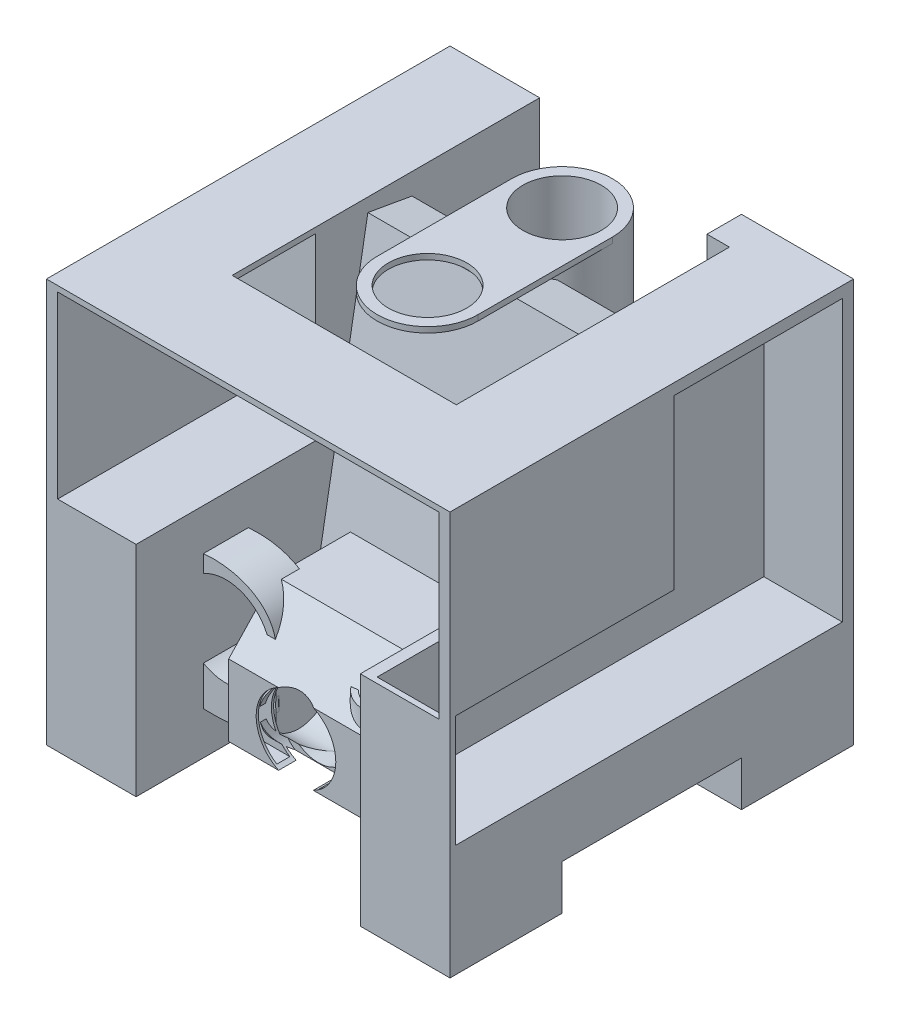
from build123d import *

# Parameters (mm, degrees)
SKETCH1_W               = 101.6
SKETCH1_H               = 457.2
BOSS_EXTRUDE1_DEPTH     = 457.2
BOSS_EXTRUDE1_2_DEPTH   = 457.2
BOSS_EXTRUDE2_DEPTH     = 127
BOSS_EXTRUDE3_DEPTH     = 127
SKETCH5_R               = 44.45
BOSS_EXTRUDE4_DEPTH     = 6.35
SKETCH6_R               = 57.15
SKETCH6_R_2             = 44.45
BOSS_EXTRUDE5_DEPTH     = 304.8
SKETCH8_R               = 50.8
BOSS_EXTRUDE6_DEPTH     = 25.4
SKETCH9_R               = 44.45
SKETCH9_R_2             = 38.1
SKETCH10_R              = 38.1
CUT_EXTRUDE4_DEPTH      = 628.365860165
SKETCH14_W              = 203.2
SKETCH14_H              = 203.2
CUT_EXTRUDE6_DEPTH      = 342.9
CUT_EXTRUDE6_DEPTH_BACK = 88.9
SKETCH15_W              = 108.742622592
SKETCH15_H              = 6.35
BOSS_EXTRUDE7_DEPTH     = 254
CUT_EXTRUDE7_DEPTH      = 88.9
SKETCH17_W              = 203.2
SKETCH17_H              = 50.8
CUT_EXTRUDE9_DEPTH      = 691.049565249
SKETCH18_W              = 39.02210791
SKETCH18_H              = 325.818088277
BOSS_EXTRUDE8_DEPTH     = 25.4
EXTRUDE_THIN1_DEPTH     = 203.2
SKETCH21_R              = 45.128499214
CUT_EXTRUDE10_DEPTH     = 25.4


with BuildPart() as part:
    # Sketch1 → Boss-Extrude1 (new body)
    with BuildSketch(Plane(origin=(0, 0, 0), x_dir=(1, 0, 0), z_dir=(0, 1, 0))):
        with Locations((-177.8, 0)):
            Rectangle(SKETCH1_W, SKETCH1_H)
    extrude(amount=BOSS_EXTRUDE1_DEPTH)


with BuildPart() as body_2:
    # Sketch1 → Boss-Extrude1 2 (new body)
    with BuildSketch(Plane(origin=(0, 0, 0), x_dir=(1, 0, 0), z_dir=(0, 1, 0))):
        with Locations((177.8, 0)):
            Rectangle(SKETCH1_W, SKETCH1_H)
    extrude(amount=BOSS_EXTRUDE1_2_DEPTH)


with BuildPart() as body_3:
    # Sketch2 → Boss-Extrude2 (new body)
    with BuildSketch(Plane(origin=(0, 0, 0), x_dir=(1, 0, 0), z_dir=(0, 1, 0))):
        Polygon((-127, 228.6), (-102.241119147, 152.4), (102.241119147, 152.4), (127, 228.6), (127, 101.6), (-127, 101.6), align=None)
    extrude(amount=BOSS_EXTRUDE2_DEPTH)


with BuildPart() as body_4:
    # Sketch3 → Boss-Extrude3 (new, symmetric)
    with BuildSketch(Plane(origin=(0, 0, 0), x_dir=(0, 0, -1), z_dir=(1, 0, 0))):
        Polygon((8.967229065, 7.870409826), (83.948512182, 433.110397577), (33.920278329, 441.931725002), (-41.061004788, 16.691737252), align=None)
    extrude(amount=BOSS_EXTRUDE3_DEPTH, both=True)



with BuildPart() as body_5:
    # Sketch5 → Boss-Extrude4 (new body)
    with BuildSketch(Plane(origin=(0, 457.2, 0), x_dir=(1, 0, 0), z_dir=(0, 1, 0))):
        with BuildLine():
            Line((57.15, 127), (57.15, -25.4))
            ThreePointArc((57.15, -25.4), (0, -82.55), (-57.15, -25.4))
            Line((-57.15, -25.4), (-57.15, 127))
            ThreePointArc((-57.15, 127), (0, 184.15), (57.15, 127))
        make_face()
        with Locations(Location((0, 127, 0), (0, 0, 270))):
            Circle(SKETCH5_R, mode=Mode.SUBTRACT)
        with Locations(Location((0, -25.4, 0), (0, 0, 270))):
            Circle(SKETCH5_R, mode=Mode.SUBTRACT)
    extrude(amount=BOSS_EXTRUDE4_DEPTH)


with BuildPart() as body_4_1:
    add(body_4.part)

    add(body_5.part)  # Boss-Extrude5 merges body 5
    # Sketch6 → Boss-Extrude5 (add)
    with BuildSketch(Plane.XZ.offset(-457.2)):
        with Locations(Location((0, -127, 0), (0, 0, 180))):
            Circle(SKETCH6_R)
        with Locations(Location((0, -127, 0), (0, 0, 90))):
            Circle(SKETCH6_R_2, mode=Mode.SUBTRACT)
    extrude(amount=BOSS_EXTRUDE5_DEPTH)


with BuildPart() as body_5_2:
    # Sketch8 → Boss-Extrude6 (new, symmetric)
    with BuildSketch(Plane.XY.offset(127)):
        with BuildLine():
            Line((-44.45, 139.7), (-44.45, 50.8))
            add(Edge.make_bspline(
                [(-44.45, 139.7), (-38.101478658, 213.420756521), (-225.699693056, 221.232205599), (-177.946955213, 28.582003497), (-110.969811874, 50.8), (-44.45, 50.8)],
                knots=[0, 0, 0, 0, 0.43256951, 0.679075741, 1, 1, 1, 1], degree=3))
        make_face()
        with Locations((-101.478081159, 136.980160233)):
            Circle(SKETCH8_R, mode=Mode.SUBTRACT)
    extrude(amount=BOSS_EXTRUDE6_DEPTH, both=True)

    # Sweep1: sweep along a path in Sketch7
    with BuildLine(Plane.XY.offset(127)) as sweep1_path:
        Line((-44.45, 95.25), (18.253880771, 95.25))
        ThreePointArc((18.253880771, 95.25), (60.931690243, 113.558193077), (77.076495404, 157.100478517))
    # Sketch9 → Sweep1 (sweep)
    with BuildSketch(Plane(origin=(-44.45, 0, 0), x_dir=(0, 0, -1), z_dir=(1, 0, 0))):
        with Locations((-127, 95.25)):
            Circle(SKETCH9_R)
        with Locations((-127, 95.25)):
            Circle(SKETCH9_R_2, mode=Mode.SUBTRACT)
    sweep(path=sweep1_path.line)

    # Sketch10 → Cut-Extrude4 (cut, through all)
    with BuildSketch(Plane.XY.offset(127)):
        with Locations(Location((0, 95.25, 0), (0, 0, 298.626930656))):
            Circle(SKETCH10_R)
    extrude(amount=CUT_EXTRUDE4_DEPTH, mode=Mode.SUBTRACT)



with BuildPart() as cut_extrude6_tool:
    # Sketch14 → Cut-Extrude6 (new, two sides)
    with BuildSketch(Plane(origin=(-127, 0, 0), x_dir=(0, 0, -1), z_dir=(1, 0, 0))) as cut_extrude6_sk:
        with Locations((-127, 349.25)):
            Rectangle(SKETCH14_W, SKETCH14_H)
    extrude(amount=CUT_EXTRUDE6_DEPTH)
    extrude(cut_extrude6_sk.sketch, amount=-CUT_EXTRUDE6_DEPTH_BACK)


with BuildPart() as part_1:
    add(part.part)

    # Cut-Extrude6: cut by cut_extrude6_tool
    add(cut_extrude6_tool.part, mode=Mode.SUBTRACT)



with BuildPart() as body_2_1:
    add(body_2.part)

    # Cut-Extrude6: cut by cut_extrude6_tool
    add(cut_extrude6_tool.part, mode=Mode.SUBTRACT)


with BuildPart() as part_2:
    add(part_1.part)

    add(body_2_1.part)  # Boss-Extrude7 merges body 2
    # Sketch15 → Boss-Extrude7 (add)
    with BuildSketch(Plane(origin=(-127, 0, 0), x_dir=(0, 0, -1), z_dir=(1, 0, 0))):
        with Locations((-174.228688704, 454.025)):
            Rectangle(SKETCH15_W, SKETCH15_H)
    extrude(amount=BOSS_EXTRUDE7_DEPTH)

    # Sketch16 → Cut-Extrude7 (cut)
    with BuildSketch(Plane(origin=(228.6, 0, 0), x_dir=(0, 0, -1), z_dir=(1, 0, 0))):
        Polygon((-222.25, 254), (-222.25, 127), (215.9, 127), (215.9, 444.5), (25.4, 444.5), (25.4, 254), align=None)
    extrude(amount=-CUT_EXTRUDE7_DEPTH, mode=Mode.SUBTRACT)


with BuildPart() as cut_extrude9_tool:
    # Sketch17 → Cut-Extrude9 (new, through all)
    with BuildSketch(Plane(origin=(228.6, 0, 0), x_dir=(0, 0, -1), z_dir=(1, 0, 0))):
        with Locations((0, 25.4)):
            Rectangle(SKETCH17_W, SKETCH17_H)
    extrude(amount=-CUT_EXTRUDE9_DEPTH)


with BuildPart() as part_3:
    add(part_2.part)

    # Cut-Extrude9: cut by cut_extrude9_tool
    add(cut_extrude9_tool.part, mode=Mode.SUBTRACT)

    # Sketch18 → Boss-Extrude8 (add)
    with BuildSketch(Plane.ZY.offset(-127)):
        with Locations((-209.088946045, 294.290955862)):
            Rectangle(SKETCH18_W, SKETCH18_H)
    extrude(amount=BOSS_EXTRUDE8_DEPTH)


with BuildPart() as body_4_2:
    add(body_4_1.part)

    # Cut-Extrude9: cut by cut_extrude9_tool
    add(cut_extrude9_tool.part, mode=Mode.SUBTRACT)


with BuildPart() as body_5_2_1:
    add(body_5_2.part)

    add(part_3.part)  # Extrude-Thin1 merges part

    add(body_4_2.part)  # Extrude-Thin1 merges body 4
    # Sketch20 → Extrude-Thin1 (add)
    with BuildSketch(Plane.ZY.offset(-127)):
        Polygon((36.58549533, 189.172680872), (36.58549533, 160.781615265), (119.173197428, 160.781615265), (154.672550865, 123.151747535), (154.672550865, 52.569763027), (174.506227862, 52.569763027), (174.506227862, 133.607242049), (122.086773034, 189.172680872), align=None)
        Polygon((39.12549533, 186.632680872), (39.12549533, 163.321615265), (120.268901455, 163.321615265), (157.212550865, 124.160771301), (157.212550865, 55.109763027), (171.966227862, 55.109763027), (171.966227862, 132.598218283), (120.991069007, 186.632680872), align=None, mode=Mode.SUBTRACT)
    extrude(amount=EXTRUDE_THIN1_DEPTH)

    # Sketch21 → Cut-Extrude10 (cut)
    with BuildSketch(Plane.XY.offset(174.506227862)):
        with Locations((0, 93.192864815)):
            Circle(SKETCH21_R)
    extrude(amount=-CUT_EXTRUDE10_DEPTH, mode=Mode.SUBTRACT)


solid = Compound([body_3.part, body_5_2_1.part])
